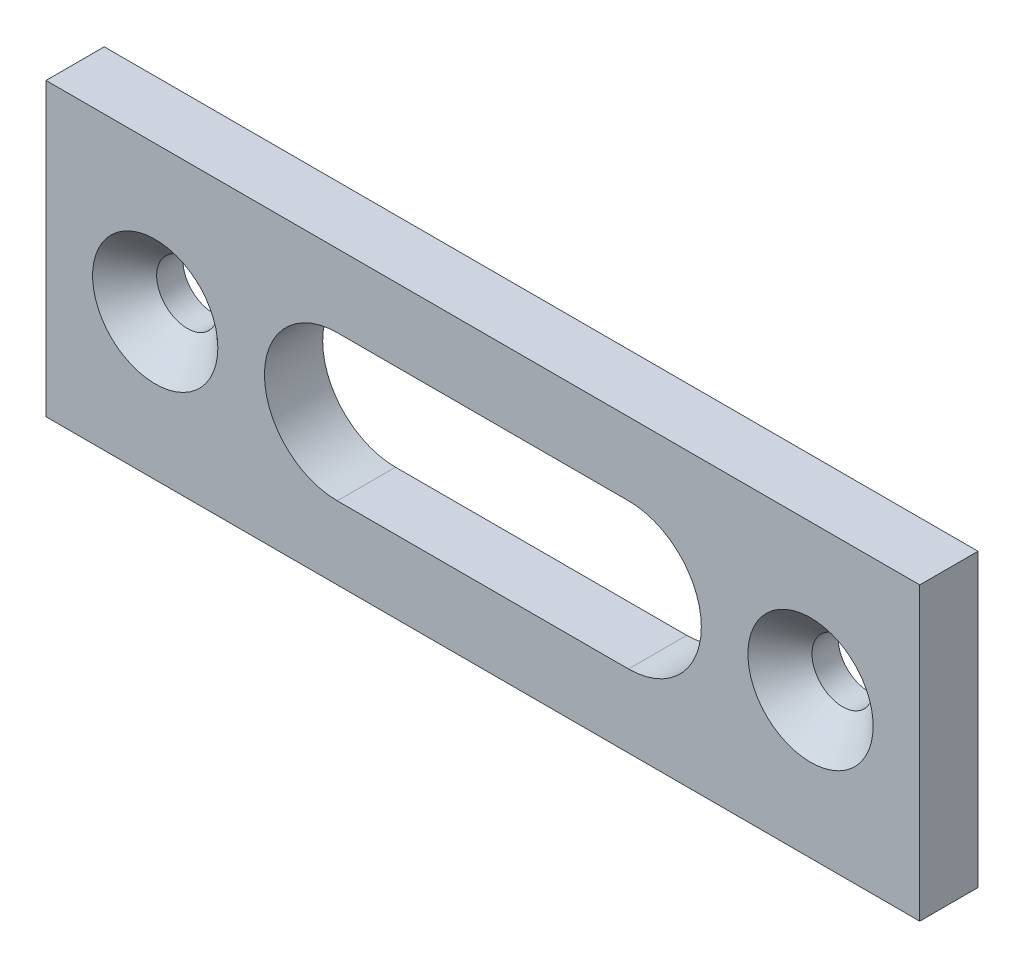
from build123d import *

# Parameters (mm, degrees)
ESQUISSE1_W      = 60
ESQUISSE1_H      = 20
ESQUISSE1_R      = 2.1
EXTRUSION1_DEPTH = 4
CHANFREIN1_SIZE  = 2.2


with BuildPart() as part:
    # Esquisse1 → Extrusion1 (new body)
    with BuildSketch(Plane.XY):
        Rectangle(ESQUISSE1_W, ESQUISSE1_H)
        with Locations((-22.5, 0)):
            Circle(ESQUISSE1_R, mode=Mode.SUBTRACT)
        with Locations((22.5, 0)):
            Circle(ESQUISSE1_R, mode=Mode.SUBTRACT)
        with BuildLine():
            Line((-10, 5), (10, 5))
            ThreePointArc((10, 5), (15, 0), (10, -5))
            Line((10, -5), (-10, -5))
            ThreePointArc((-10, -5), (-15, 0), (-10, 5))
        make_face(mode=Mode.SUBTRACT)
    extrude(amount=EXTRUSION1_DEPTH)

    # Chanfrein1
    chanfrein1_edges = [part.edges().sort_by_distance(p)[0] for p in [
        (-24.6, 0, 4),
        (20.4, 0, 4),
    ]]
    chamfer(chanfrein1_edges, length=CHANFREIN1_SIZE)


solid = part.part
